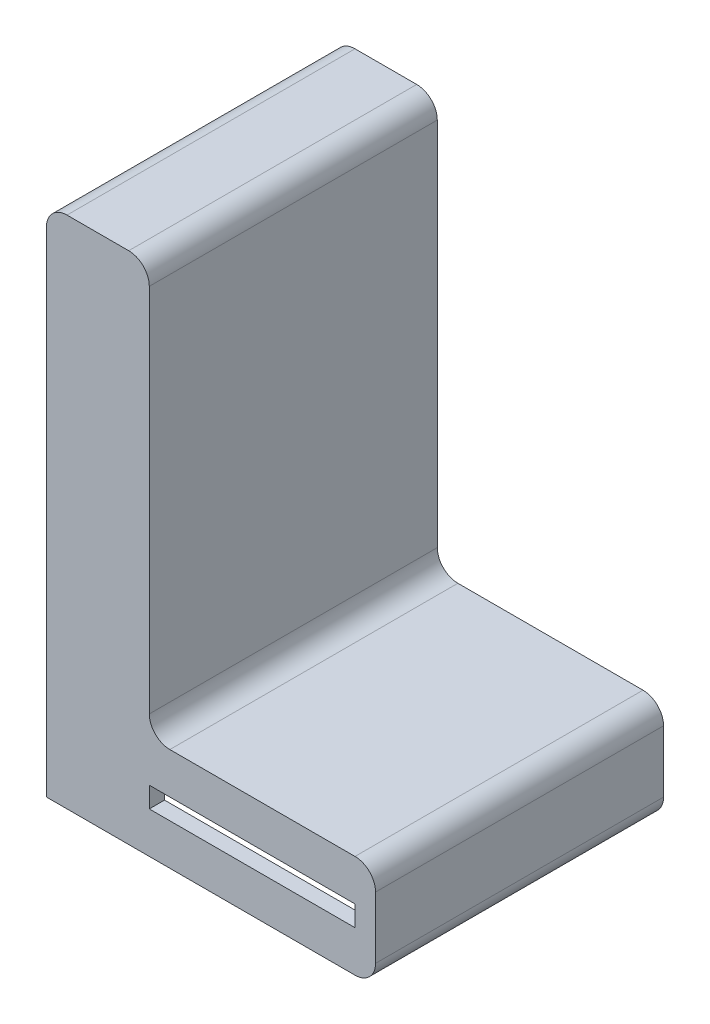
from build123d import *

# Parameters (mm, degrees)
BOSS_EXTRUDE3_DEPTH = 14
SKETCH3_W           = 13.981436564
SKETCH3_H           = 12.786132402
CUT_EXTRUDE2_DEPTH  = 4
SKETCH4_W           = 10
SKETCH4_H           = 1
CUT_EXTRUDE3_DEPTH  = 4
SKETCH5_W           = 8
SKETCH5_H           = 1
CUT_EXTRUDE4_DEPTH  = 4
SKETCH6_W           = 1.942983733
SKETCH6_H           = 1
CUT_EXTRUDE5_DEPTH  = 4


with BuildPart() as part:
    # Sketch1 → Boss-Extrude3 (new body)
    with BuildSketch(Plane.XY):
        with BuildLine():
            Line((0, 24), (0, 0))
            Line((0, 0), (15, 0))
            ThreePointArc((15, 0), (15.707106781, 0.292893219), (16, 1))
            Line((16, 1), (16, 4))
            ThreePointArc((16, 4), (15.707106781, 4.707106781), (15, 5))
            Line((15, 5), (6, 5))
            ThreePointArc((6, 5), (5.292893219, 5.292893219), (5, 6))
            Line((5, 6), (5, 24))
            ThreePointArc((5, 24), (4.707106781, 24.707106781), (4, 25))
            Line((4, 25), (1, 25))
            ThreePointArc((1, 25), (0.292893219, 24.707106781), (0, 24))
        make_face()
    extrude(amount=BOSS_EXTRUDE3_DEPTH)

    # Sketch3 → Cut-Extrude2 (cut)
    with BuildSketch(Plane.XZ):
        with Locations((7.674007956, 6.864169982)):
            Rectangle(SKETCH3_W, SKETCH3_H)
    extrude(amount=-CUT_EXTRUDE2_DEPTH, mode=Mode.SUBTRACT)

    # Sketch4 → Cut-Extrude3 (cut)
    with BuildSketch(Plane.XY.offset(14)):
        with Locations((10, 2.5)):
            Rectangle(SKETCH4_W, SKETCH4_H)
    extrude(amount=-CUT_EXTRUDE3_DEPTH, mode=Mode.SUBTRACT)

    # Sketch5 → Cut-Extrude4 (cut)
    with BuildSketch(Plane(origin=(0, 0, 0), x_dir=(-1, 0, 0), z_dir=(0, 0, -1))):
        with Locations((-11, 2.5)):
            Rectangle(SKETCH5_W, SKETCH5_H)
    extrude(amount=-CUT_EXTRUDE4_DEPTH, mode=Mode.SUBTRACT)

    # Sketch6 → Cut-Extrude5 (cut)
    with BuildSketch(Plane(origin=(0, 0, 0), x_dir=(-1, 0, 0), z_dir=(0, 0, -1))):
        with Locations((-6.028508134, 2.5)):
            Rectangle(SKETCH6_W, SKETCH6_H)
    extrude(amount=-CUT_EXTRUDE5_DEPTH, mode=Mode.SUBTRACT)


solid = part.part
